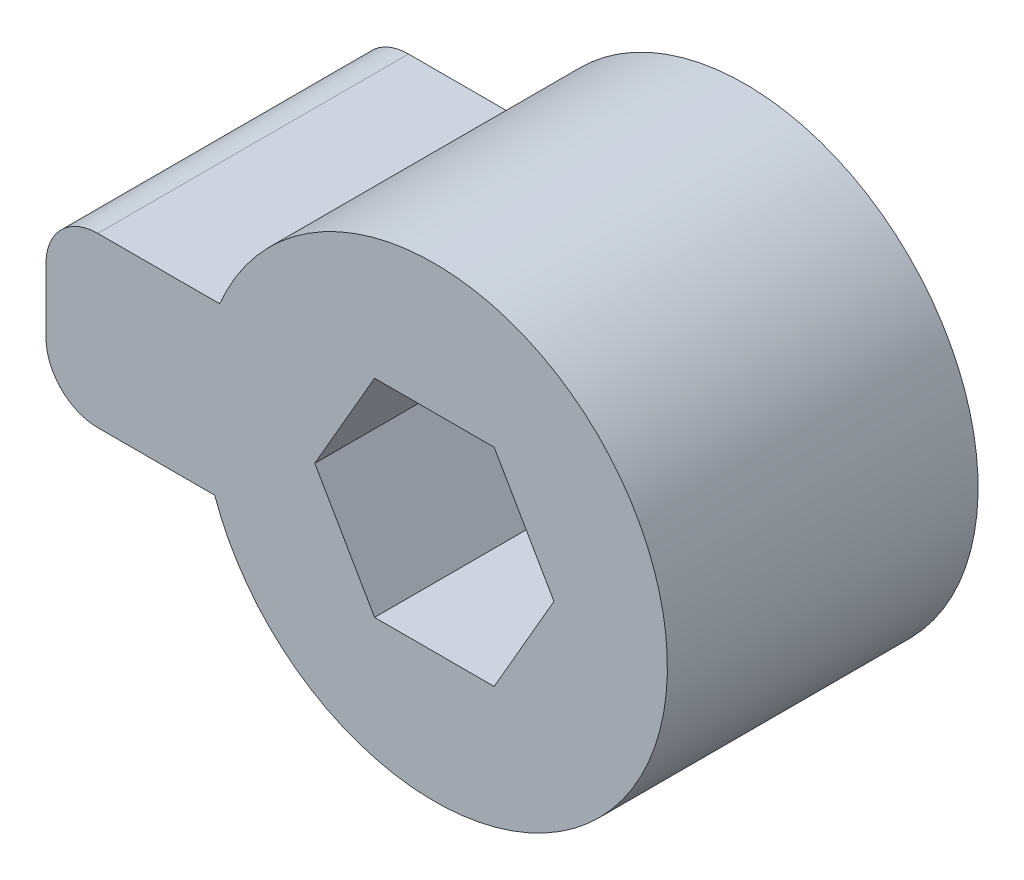
from build123d import *

# Parameters (mm, degrees)
SKETCH1_R                = 4.5
BOSS_EXTRUDE1_DEPTH      = 6
BOSS_EXTRUDE2_DEPTH      = 1.75
BOSS_EXTRUDE2_DEPTH_BACK = 1.5
FILLET1_R                = 1


with BuildPart() as part:
    # Sketch1 → Boss-Extrude1 (new body)
    with BuildSketch(Plane.XY):
        with Locations((5.549376682, 2)):
            Circle(SKETCH1_R)
        Polygon((4.394676144, 0), (6.704077221, 0), (7.858777759, 2), (6.704077221, 4), (4.394676144, 4), (3.239975606, 2), align=None, mode=Mode.SUBTRACT)
    extrude(amount=BOSS_EXTRUDE1_DEPTH)

    # Sketch2 → Boss-Extrude2 (add, two sides)
    with BuildSketch(Plane(origin=(0, 2, 0), x_dir=(1, 0, 0), z_dir=(0, 1, 0))) as boss_extrude2_sk:
        Polygon((3.239975606, 0), (1.049376682, 0), (-1.950623318, 0), (-1.950623318, -6), (1.049376682, -6), (3.239975606, -6), align=None)
    extrude(amount=BOSS_EXTRUDE2_DEPTH)
    extrude(boss_extrude2_sk.sketch, amount=-BOSS_EXTRUDE2_DEPTH_BACK)

    # Fillet1
    fillet1_edges = [part.edges().sort_by_distance(p)[0] for p in [
        (-1.950623318, 3.75, 3),
        (-1.950623318, 0.5, 3),
    ]]
    fillet(fillet1_edges, radius=FILLET1_R)


solid = part.part
